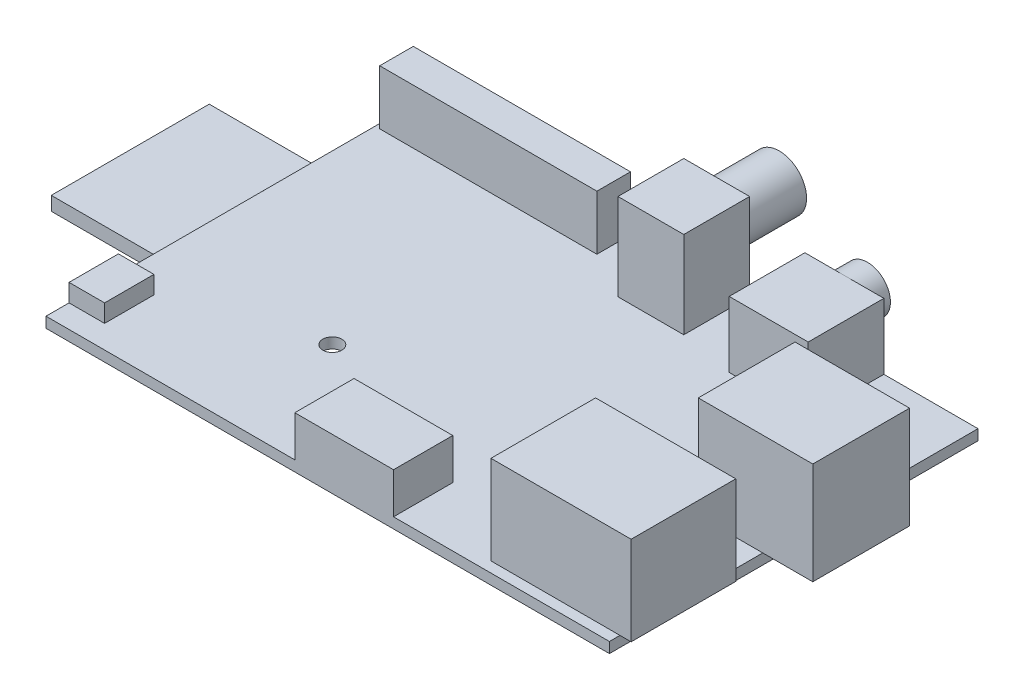
from build123d import *

# Parameters (mm, degrees)
SKETCH1_W            = 85.6
SKETCH1_H            = 56
BOSS_EXTRUDE1_DEPTH  = 1.6
SKETCH2_W            = 21.3
SKETCH2_H            = 15.9
BOSS_EXTRUDE2_DEPTH  = 13.5
SKETCH3_W            = 17.4
SKETCH3_H            = 14.7
BOSS_EXTRUDE3_DEPTH  = 15.5
SKETCH4_W            = 16.8
SKETCH4_H            = 28.8
BOSS_EXTRUDE4_DEPTH  = 3.4
SKETCH5_W            = 24
SKETCH5_H            = 2.1
BOSS_EXTRUDE5_DEPTH  = 17.7
SKETCH6_W            = 10
SKETCH6_H            = 10
BOSS_EXTRUDE6_DEPTH  = 13.2
SKETCH7_R            = 4.15
BOSS_EXTRUDE7_DEPTH  = 9.5
SKETCH8_W            = 12
SKETCH8_H            = 11.5
BOSS_EXTRUDE8_DEPTH  = 10
SKETCH9_R            = 3.5
BOSS_EXTRUDE9_DEPTH  = 3.5
SKETCH10_W           = 33
SKETCH10_H           = 5.1
BOSS_EXTRUDE10_DEPTH = 8.3
SKETCH11_W           = 5.4
SKETCH11_H           = 7.5
BOSS_EXTRUDE11_DEPTH = 2.7
SKETCH12_W           = 15
SKETCH12_H           = 9
BOSS_EXTRUDE12_DEPTH = 6.2
SKETCH13_R           = 1.45
CUT_EXTRUDE1_DEPTH   = 6


with BuildPart() as part:
    # Sketch1 → Boss-Extrude1 (new body)
    with BuildSketch(Plane(origin=(0, 0, 0), x_dir=(1, 0, 0), z_dir=(0, 1, 0))):
        Rectangle(SKETCH1_W, SKETCH1_H)
    extrude(amount=BOSS_EXTRUDE1_DEPTH)

    # Sketch2 → Boss-Extrude2 (add)
    with BuildSketch(Plane(origin=(0, 1.6, 0), x_dir=(1, 0, 0), z_dir=(0, 1, 0))):
        with Locations((33.85, -18.45)):
            Rectangle(SKETCH2_W, SKETCH2_H)
    extrude(amount=BOSS_EXTRUDE2_DEPTH)

    # Sketch3 → Boss-Extrude3 (add)
    with BuildSketch(Plane(origin=(0, 1.6, 0), x_dir=(1, 0, 0), z_dir=(0, 1, 0))):
        with Locations((41.7, 2.65)):
            Rectangle(SKETCH3_W, SKETCH3_H)
    extrude(amount=BOSS_EXTRUDE3_DEPTH)

    # Sketch4 → Boss-Extrude4 (add)
    with BuildSketch(Plane.XZ):
        with Locations((-34.4, -1.5)):
            Rectangle(SKETCH4_W, SKETCH4_H)
    extrude(amount=BOSS_EXTRUDE4_DEPTH)

    # Sketch5 → Boss-Extrude5 (add)
    with BuildSketch(Plane.ZY.offset(42.8)):
        with Locations((-2.5, -1.65)):
            Rectangle(SKETCH5_W, SKETCH5_H)
    extrude(amount=BOSS_EXTRUDE5_DEPTH)

    # Sketch6 → Boss-Extrude6 (add)
    with BuildSketch(Plane(origin=(0, 1.6, 0), x_dir=(1, 0, 0), z_dir=(0, 1, 0))):
        with Locations((3.1, 23)):
            Rectangle(SKETCH6_W, SKETCH6_H)
    extrude(amount=BOSS_EXTRUDE6_DEPTH)

    # Sketch7 → Boss-Extrude7 (add)
    with BuildSketch(Plane(origin=(0, 0, -28), x_dir=(-1, 0, 0), z_dir=(0, 0, -1))):
        with Locations((-3.1, 9.4)):
            Circle(SKETCH7_R)
    extrude(amount=BOSS_EXTRUDE7_DEPTH)

    # Sketch8 → Boss-Extrude8 (add)
    with BuildSketch(Plane(origin=(0, 1.6, 0), x_dir=(1, 0, 0), z_dir=(0, 1, 0))):
        with Locations((22.5, 22.25)):
            Rectangle(SKETCH8_W, SKETCH8_H)
    extrude(amount=BOSS_EXTRUDE8_DEPTH)

    # Sketch9 → Boss-Extrude9 (add)
    with BuildSketch(Plane(origin=(0, 0, -28), x_dir=(-1, 0, 0), z_dir=(0, 0, -1))):
        with Locations((-22.5, 8.1)):
            Circle(SKETCH9_R)
    extrude(amount=BOSS_EXTRUDE9_DEPTH)

    # Sketch10 → Boss-Extrude10 (add)
    with BuildSketch(Plane(origin=(0, 1.6, 0), x_dir=(1, 0, 0), z_dir=(0, 1, 0))):
        with Locations((-25.6, 24.55)):
            Rectangle(SKETCH10_W, SKETCH10_H)
    extrude(amount=BOSS_EXTRUDE10_DEPTH)

    # Sketch11 → Boss-Extrude11 (add)
    with BuildSketch(Plane(origin=(0, 1.6, 0), x_dir=(1, 0, 0), z_dir=(0, 1, 0))):
        with Locations((-40.1, -20.75)):
            Rectangle(SKETCH11_W, SKETCH11_H)
    extrude(amount=BOSS_EXTRUDE11_DEPTH)

    # Sketch12 → Boss-Extrude12 (add)
    with BuildSketch(Plane(origin=(0, 1.6, 0), x_dir=(1, 0, 0), z_dir=(0, 1, 0))):
        with Locations((2.5, -23.5)):
            Rectangle(SKETCH12_W, SKETCH12_H)
    extrude(amount=BOSS_EXTRUDE12_DEPTH)

    # Sketch13 → Cut-Extrude1 (cut, through all)
    with BuildSketch(Plane(origin=(0, 1.6, 0), x_dir=(1, 0, 0), z_dir=(0, 1, 0))):
        with Locations((-17.3, -10)):
            Circle(SKETCH13_R)
        with Locations((37.8, 15.5)):
            Circle(SKETCH13_R)
    extrude(amount=-CUT_EXTRUDE1_DEPTH, mode=Mode.SUBTRACT)


solid = part.part
